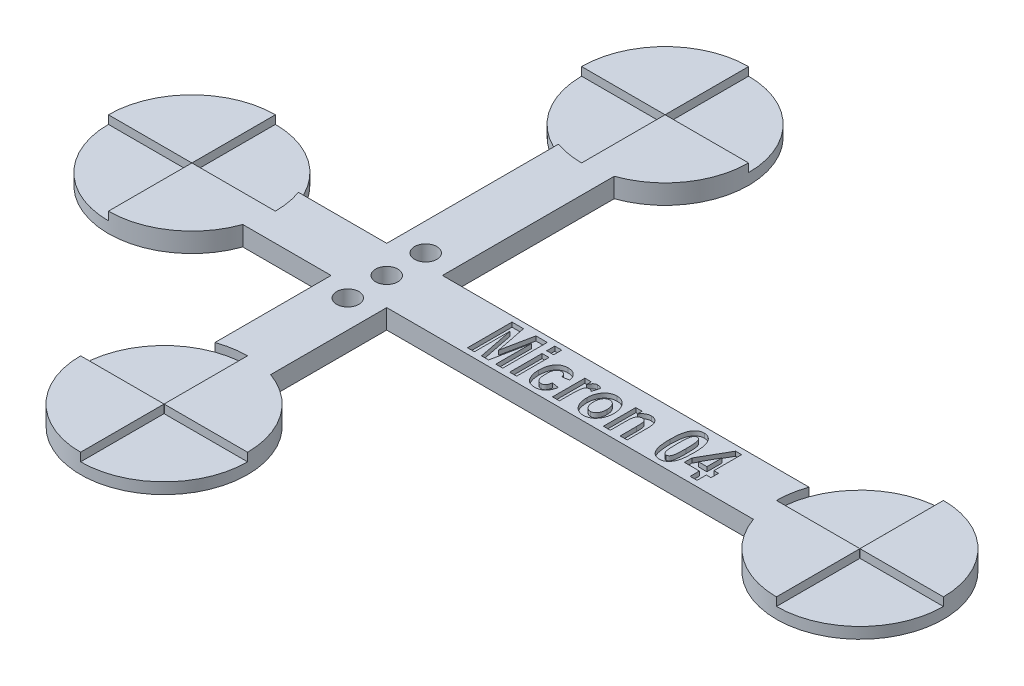
from build123d import *

# Parameters (mm, degrees)
BOSS_EXTRUDE1_DEPTH = 3.5
CUT_EXTRUDE1_DEPTH  = 1.5
SKETCH3_W           = 1.246753247
SKETCH3_H           = 1.454545455
SKETCH3_H_2         = 5.818181818
CUT_EXTRUDE2_DEPTH  = 0.8
SKETCH4_R           = 2
CUT_EXTRUDE3_DEPTH  = 4.5


with BuildPart() as part:
    # Sketch1 → Boss-Extrude1 (new body)
    with BuildSketch(Plane(origin=(0, 0, 0), x_dir=(1, 0, 0), z_dir=(0, 1, 0))):
        with BuildLine():
            Line((30, 35.857864376), (30, 5))
            Line((30, 5), (14.142135624, 5))
            ThreePointArc((14.142135624, 5), (-15, 0), (14.142135624, -5))
            Line((14.142135624, -5), (30, -5))
            Line((30, -5), (30, -25.857864376))
            ThreePointArc((30, -25.857864376), (35, -55), (40, -25.857864376))
            Line((40, -25.857864376), (40, -5))
            Line((40, -5), (105.857864376, -5))
            ThreePointArc((105.857864376, -5), (135, 0), (105.857864376, 5))
            Line((105.857864376, 5), (40, 5))
            Line((40, 5), (40, 35.857864376))
            ThreePointArc((40, 35.857864376), (35, 65), (30, 35.857864376))
        make_face()
    extrude(amount=BOSS_EXTRUDE1_DEPTH)

    # Sketch2 → Cut-Extrude1 (cut)
    with BuildSketch(Plane(origin=(0, 3.5, 0), x_dir=(1, 0, 0), z_dir=(0, 1, 0))):
        with BuildLine():
            Line((-15, 0), (-0.05, 0))
            ThreePointArc((-0.05, 0), (-0.035355339, 0.035355339), (0, 0.05))
            Line((0, 0.05), (0, 15))
            ThreePointArc((0, 15), (10.606601718, 10.606601718), (15, 0))
            Line((15, 0), (0.05, 0))
            ThreePointArc((0.05, 0), (0.035355339, -0.035355339), (0, -0.05))
            Line((0, -0.05), (0, -15))
            ThreePointArc((0, -15), (-10.606601718, -10.606601718), (-15, 0))
        make_face()
        with BuildLine():
            Line((35, 65), (35, 50.05))
            ThreePointArc((35, 50.05), (34.964644661, 50.035355339), (34.95, 50))
            Line((34.95, 50), (20, 50))
            ThreePointArc((20, 50), (24.393398282, 39.393398282), (35, 35))
            Line((35, 35), (35, 49.95))
            ThreePointArc((35, 49.95), (35.035355339, 49.964644661), (35.05, 50))
            Line((35.05, 50), (50, 50))
            ThreePointArc((50, 50), (45.606601718, 60.606601718), (35, 65))
        make_face()
        with BuildLine():
            Line((120, 15), (120, 0.05))
            ThreePointArc((120, 0.05), (120.035355339, 0.035355339), (120.05, 0))
            Line((120.05, 0), (135, 0))
            ThreePointArc((135, 0), (130.606601718, -10.606601718), (120, -15))
            Line((120, -15), (120, -0.05))
            ThreePointArc((120, -0.05), (119.964644661, -0.035355339), (119.95, 0))
            Line((119.95, 0), (105, 0))
            ThreePointArc((105, 0), (109.393398282, 10.606601718), (120, 15))
        make_face()
        with BuildLine():
            Line((20, -40), (34.95, -40))
            ThreePointArc((34.95, -40), (34.964644661, -40.035355339), (35, -40.05))
            Line((35, -40.05), (35, -55))
            ThreePointArc((35, -55), (45.606601718, -50.606601718), (50, -40))
            Line((50, -40), (35.05, -40))
            ThreePointArc((35.05, -40), (35.035355339, -39.964644661), (35, -39.95))
            Line((35, -39.95), (35, -25))
            ThreePointArc((35, -25), (24.393398282, -29.393398282), (20, -40))
        make_face()
    extrude(amount=-CUT_EXTRUDE1_DEPTH, mode=Mode.SUBTRACT)

    # Sketch3 → Cut-Extrude2 (cut)
    with BuildSketch(Plane(origin=(0, 3.5, 0), x_dir=(1, 0, 0), z_dir=(0, 1, 0))):
        Polygon((53.50036076, -4), (53.50036076, 4), (55.563672448, 4), (56.669191928, -1.561688312), (57.795815305, 4), (59.838023097, 4), (59.838023097, -4), (58.59126985, -4), (58.59126985, 2.400974026), (57.290945175, -4), (56.023088032, -4), (54.747114006, 2.400974026), (54.747114006, -4), align=None)
        with Locations((61.708152968, 3.376623377)):
            Rectangle(SKETCH3_W, SKETCH3_H)
        with Locations((61.708152968, -1.090909091)):
            Rectangle(SKETCH3_W, SKETCH3_H_2)
        with BuildLine():
            Line((67.734126993, 0.155844156), (66.487373747, -0.051948052))
            add(Edge.make_bspline(
                [(66.487373747, -0.051948052), (66.475238631, 0.013492139), (66.452160271, 0.137945199), (66.389179941, 0.307989308), (66.312160634, 0.454611766), (66.213055442, 0.573886506), (66.095416345, 0.667213464), (65.958609537, 0.733166985), (65.803936467, 0.772456922), (65.694860886, 0.776912369), (65.638347773, 0.779220779)],
                knots=[0, 0, 0, 0, 0.000199325, 0.000379073, 0.0005418, 0.000693948, 0.000840745, 0.000988855, 0.001146348, 0.001315678, 0.001315678, 0.001315678, 0.001315678], degree=3))
            add(Edge.make_bspline(
                [(65.638347773, 0.779220779), (65.600905429, 0.778062939), (65.527122523, 0.775781331), (65.420010496, 0.755102855), (65.317553938, 0.725549098), (65.222958212, 0.677663569), (65.130758823, 0.622007918), (65.046957124, 0.549315551), (64.968136169, 0.465515202), (64.894709448, 0.369037743), (64.827095322, 0.257785931), (64.770603047, 0.128257783), (64.725083376, -0.018687378), (64.68335517, -0.181979253), (64.653655963, -0.363419746), (64.633180941, -0.562384664), (64.620101663, -0.77850796), (64.618220871, -0.928551854), (64.617243876, -1.006493506)],
                knots=[0, 0, 0, 0, 0.000112201, 0.0002211, 0.00032637, 0.000430923, 0.000538128, 0.000648708, 0.000762403, 0.000882861, 0.001011764, 0.001152033, 0.001305535, 0.001472868, 0.001657284, 0.001856457, 0.002072757, 0.002306574, 0.002306574, 0.002306574, 0.002306574], degree=3))
            add(Edge.make_bspline(
                [(64.617243876, -1.006493506), (64.618261217, -1.092546265), (64.620213954, -1.257720471), (64.632711779, -1.496116795), (64.65538517, -1.714396148), (64.685469478, -1.914085761), (64.725675307, -2.093641007), (64.774055334, -2.254680712), (64.831596703, -2.395907747), (64.899086485, -2.518208897), (64.974173657, -2.623094471), (65.056196277, -2.712538943), (65.142228328, -2.791034021), (65.2374127, -2.851962864), (65.336627186, -2.901864568), (65.442857496, -2.935934853), (65.55464497, -2.95784839), (65.631749283, -2.959966029), (65.670815305, -2.961038961)],
                knots=[0, 0, 0, 0, 0.000258163, 0.000495531, 0.000715862, 0.000916302, 0.00110101, 0.001267389, 0.001420236, 0.001557572, 0.001685521, 0.001806187, 0.001921184, 0.002033748, 0.002144102, 0.002253448, 0.002367432, 0.002484495, 0.002484495, 0.002484495, 0.002484495], degree=3))
            add(Edge.make_bspline(
                [(65.670815305, -2.961038961), (65.72855094, -2.958115137), (65.840148837, -2.952463643), (65.998917272, -2.902884688), (66.141871425, -2.82385793), (66.244914469, -2.730611667), (66.318466989, -2.639969699), (66.370108431, -2.557981246), (66.418545215, -2.464077917), (66.462084604, -2.358060987), (66.501266248, -2.240396767), (66.534349316, -2.110465037), (66.565645908, -1.968673701), (66.582502685, -1.869672225), (66.59126985, -1.818181818)],
                knots=[0, 0, 0, 0, 0.000172842, 0.000334088, 0.000493972, 0.000659525, 0.000747247, 0.000843616, 0.000949622, 0.001063883, 0.001187088, 0.001321358, 0.001465921, 0.001622591, 0.001622591, 0.001622591, 0.001622591], degree=3))
            Line((66.59126985, -1.818181818), (67.838023097, -2.025974026))
            add(Edge.make_bspline(
                [(67.838023097, -2.025974026), (67.821015846, -2.110033143), (67.787894315, -2.273737832), (67.725282574, -2.51019173), (67.648292222, -2.729306841), (67.562922764, -2.933353422), (67.465367894, -3.120817392), (67.35648555, -3.292169834), (67.236010198, -3.447294215), (67.103969601, -3.586117196), (66.960430352, -3.708703947), (66.805564143, -3.814231607), (66.640086257, -3.904896068), (66.462835354, -3.977226655), (66.274845438, -4.034537616), (66.075882267, -4.074640125), (65.865713047, -4.099528833), (65.721752457, -4.102417816), (65.648088032, -4.103896104)],
                knots=[0, 0, 0, 0, 0.000257263, 0.000501018, 0.000733076, 0.000953485, 0.001164055, 0.001366255, 0.001561742, 0.001752349, 0.001940051, 0.002126916, 0.002313611, 0.002505046, 0.002700189, 0.002902356, 0.003113183, 0.003334111, 0.003334111, 0.003334111, 0.003334111], degree=3))
            add(Edge.make_bspline(
                [(65.648088032, -4.103896104), (65.554819841, -4.101887492), (65.37321271, -4.097976423), (65.110471697, -4.053593587), (64.864673186, -3.987367001), (64.639207309, -3.888476021), (64.431834059, -3.764176577), (64.243759839, -3.611361294), (64.073517705, -3.431602628), (63.925921273, -3.224317401), (63.795814013, -2.999463478), (63.681997355, -2.762165056), (63.585965745, -2.513438303), (63.506034653, -2.254410985), (63.446476255, -1.98270864), (63.403410095, -1.700737492), (63.374039392, -1.407542533), (63.371686907, -1.208406699), (63.37049063, -1.107142857)],
                knots=[0, 0, 0, 0, 0.000279523, 0.000544272, 0.000797144, 0.001041429, 0.001280302, 0.001520398, 0.001766145, 0.002020725, 0.002281892, 0.002544739, 0.002809429, 0.003081077, 0.00335717, 0.003643018, 0.003936526, 0.004240206, 0.004240206, 0.004240206, 0.004240206], degree=3))
            add(Edge.make_bspline(
                [(63.37049063, -1.107142857), (63.372239743, -0.987488549), (63.375640625, -0.75483916), (63.405336818, -0.417027711), (63.452726945, -0.100401237), (63.522926455, 0.193547978), (63.609847208, 0.466113039), (63.716501303, 0.716580192), (63.846096582, 0.943069469), (63.991820845, 1.149170928), (64.156114523, 1.330213011), (64.331961705, 1.489088097), (64.520060194, 1.623763244), (64.721234776, 1.733258723), (64.935011157, 1.818073271), (65.160732658, 1.877319248), (65.397782122, 1.916873853), (65.560259998, 1.920318934), (65.643217902, 1.922077922)],
                knots=[0, 0, 0, 0, 0.000358898, 0.000697823, 0.001016501, 0.00131851, 0.001603435, 0.001873935, 0.002133483, 0.002384849, 0.002629678, 0.002865336, 0.003094623, 0.003322001, 0.003550805, 0.003782743, 0.004021075, 0.004269712, 0.004269712, 0.004269712, 0.004269712], degree=3))
            add(Edge.make_bspline(
                [(65.643217902, 1.922077922), (65.71035858, 1.920846466), (65.841687336, 1.918437708), (66.034520622, 1.899106266), (66.217142954, 1.864581364), (66.391368457, 1.819675788), (66.554972261, 1.759740953), (66.709026878, 1.685791916), (66.853826329, 1.599814288), (66.98980103, 1.500415487), (67.115185036, 1.385394066), (67.233134509, 1.256930605), (67.340019014, 1.110862201), (67.439342218, 0.950708523), (67.526615855, 0.773374249), (67.606095879, 0.582082787), (67.676087051, 0.374743093), (67.714406275, 0.230221286), (67.734126993, 0.155844156)],
                knots=[0, 0, 0, 0, 0.000201403, 0.00039395, 0.000580532, 0.000758512, 0.000933129, 0.001102311, 0.00127047, 0.001437685, 0.001606618, 0.001780137, 0.00196001, 0.002148783, 0.002344802, 0.00255222, 0.002769885, 0.003000685, 0.003000685, 0.003000685, 0.003000685], degree=3))
        make_face()
        with BuildLine():
            Line((70.019841279, -4), (68.773088032, -4))
            Line((68.773088032, -4), (68.773088032, 1.818181818))
            Line((68.773088032, 1.818181818), (69.915945175, 1.818181818))
            Line((69.915945175, 1.818181818), (69.915945175, 0.991883117))
            add(Edge.make_bspline(
                [(69.915945175, 0.991883117), (69.940159399, 1.037952881), (69.986797897, 1.126686869), (70.05617644, 1.253336089), (70.123683954, 1.367923953), (70.192594719, 1.467096929), (70.254997633, 1.556811947), (70.319023898, 1.631359029), (70.379881779, 1.694731582), (70.457465413, 1.762170073), (70.560087337, 1.826053482), (70.691232303, 1.882473547), (70.832643067, 1.915363311), (70.929848968, 1.919815142), (70.979256863, 1.922077922)],
                knots=[0, 0, 0, 0, 0.000156131, 0.000300721, 0.000433243, 0.000554812, 0.000662946, 0.000760848, 0.000849244, 0.000926367, 0.001068679, 0.001209792, 0.001353128, 0.001501291, 0.001501291, 0.001501291, 0.001501291], degree=3))
            add(Edge.make_bspline(
                [(70.979256863, 1.922077922), (71.049468143, 1.91886318), (71.189930484, 1.912431875), (71.396264458, 1.852623193), (71.598585759, 1.762131289), (71.72239596, 1.675863479), (71.786075045, 1.631493506)],
                knots=[0, 0, 0, 0, 0.000210176, 0.00042047, 0.000639866, 0.000872208, 0.000872208, 0.000872208, 0.000872208], degree=3))
            Line((71.786075045, 1.631493506), (71.391594526, 0.319805195))
            add(Edge.make_bspline(
                [(71.391594526, 0.319805195), (71.343457298, 0.358255441), (71.252471756, 0.430931343), (71.106176233, 0.509110372), (70.96429064, 0.560954838), (70.869258342, 0.568020125), (70.823412708, 0.571428571)],
                knots=[0, 0, 0, 0, 0.000184416, 0.00034857, 0.000495904, 0.00063323, 0.00063323, 0.00063323, 0.00063323], degree=3))
            add(Edge.make_bspline(
                [(70.823412708, 0.571428571), (70.782505012, 0.569577552), (70.701066257, 0.565892554), (70.584319511, 0.525699903), (70.474380215, 0.46484784), (70.373247856, 0.375884101), (70.28120342, 0.255501948), (70.208770468, 0.094601523), (70.146148418, -0.102439271), (70.107437305, -0.295455124), (70.083085691, -0.477538767), (70.06505598, -0.645297865), (70.050951083, -0.839680763), (70.040281294, -1.060551746), (70.030100881, -1.307830134), (70.023930168, -1.582222395), (70.021131213, -1.883652001), (70.020282911, -2.093614232), (70.019841279, -2.202922078)],
                knots=[0, 0, 0, 0, 0.000122282, 0.000243439, 0.00036627, 0.000497452, 0.000644536, 0.000817347, 0.001023727, 0.001264102, 0.001406673, 0.001574831, 0.001770184, 0.001991255, 0.002238201, 0.002512628, 0.002814594, 0.00314252, 0.00314252, 0.00314252, 0.00314252], degree=3))
            Line((70.019841279, -2.202922078), (70.019841279, -4))
        make_face()
        with BuildLine():
            add(Edge.make_bspline(
                [(71.993867253, -1.00974026), (71.99773938, -0.871492577), (72.005358765, -0.599455473), (72.07087566, -0.202105645), (72.173904845, 0.177168447), (72.298261932, 0.475142281), (72.414852128, 0.700213025), (72.508933594, 0.858166819), (72.610211845, 1.0047968), (72.716400181, 1.140905493), (72.830224235, 1.265802708), (72.948905998, 1.380456268), (73.075551332, 1.483975824), (73.251872281, 1.606243165), (73.48640792, 1.734106031), (73.786697572, 1.843482079), (74.103960535, 1.910979968), (74.321452502, 1.918333961), (74.432178941, 1.922077922)],
                knots=[0, 0, 0, 0, 0.000414499, 0.00081563, 0.001204757, 0.001591247, 0.00178148, 0.00196495, 0.002142367, 0.002315787, 0.002482426, 0.002648908, 0.002810415, 0.002972534, 0.003292157, 0.00360852, 0.00392849, 0.004260331, 0.004260331, 0.004260331, 0.004260331], degree=3))
            add(Edge.make_bspline(
                [(74.432178941, 1.922077922), (74.524844362, 1.919080026), (74.706214487, 1.913212371), (74.970819979, 1.872921067), (75.219608224, 1.802229151), (75.453953528, 1.705294578), (75.670723745, 1.576365199), (75.874437856, 1.423442467), (76.059923504, 1.239208288), (76.228428557, 1.030627633), (76.37997441, 0.803981072), (76.513296238, 0.565748818), (76.625008798, 0.317712454), (76.719657136, 0.061815795), (76.787549524, -0.205805812), (76.840332848, -0.481537671), (76.871889339, -0.767122546), (76.87526987, -0.960420315), (76.876984136, -1.058441558)],
                knots=[0, 0, 0, 0, 0.000277982, 0.000544082, 0.000800519, 0.001052268, 0.001302568, 0.001555169, 0.001814604, 0.002084622, 0.002358372, 0.002631625, 0.002902613, 0.00317376, 0.003448993, 0.003729814, 0.004015574, 0.004309567, 0.004309567, 0.004309567, 0.004309567], degree=3))
            add(Edge.make_bspline(
                [(76.876984136, -1.058441558), (76.876227692, -1.131529258), (76.874729677, -1.276267575), (76.857345801, -1.490737935), (76.832372892, -1.700083082), (76.794451847, -1.904353031), (76.74632035, -2.102762528), (76.686787225, -2.295895078), (76.619804227, -2.484139081), (76.53955722, -2.665021822), (76.453170655, -2.838694854), (76.356567034, -3.000287959), (76.256676902, -3.152976813), (76.14667086, -3.291813358), (76.033747016, -3.423233057), (75.911462009, -3.541439921), (75.783056626, -3.649149424), (75.604551972, -3.775655653), (75.369934842, -3.906802618), (75.071483883, -4.020332864), (74.759616253, -4.091116904), (74.546182896, -4.0996153), (74.438672448, -4.103896104)],
                knots=[0, 0, 0, 0, 0.00021921, 0.00043411, 0.00064513, 0.000851458, 0.001056987, 0.001257262, 0.001457537, 0.001655994, 0.001850563, 0.002039049, 0.002220497, 0.002397475, 0.002570043, 0.002739947, 0.002907061, 0.003072374, 0.003395769, 0.003710226, 0.004027699, 0.00434993, 0.00434993, 0.00434993, 0.00434993], degree=3))
            add(Edge.make_bspline(
                [(74.438672448, -4.103896104), (74.352502729, -4.101341217), (74.183124459, -4.096319241), (73.934716636, -4.058456248), (73.698054839, -3.99479852), (73.472549003, -3.90676201), (73.258016744, -3.793542556), (73.054181778, -3.655526311), (72.864029071, -3.488983811), (72.683779026, -3.302138577), (72.520670531, -3.090331966), (72.380150134, -2.855461331), (72.258457363, -2.600481865), (72.162310721, -2.322961565), (72.085543251, -2.024985427), (72.033233234, -1.70496049), (72.000302919, -1.364326972), (71.996049016, -1.12994916), (71.993867253, -1.00974026)],
                knots=[0, 0, 0, 0, 0.000258443, 0.000508006, 0.000751761, 0.000992327, 0.001232686, 0.001478079, 0.001728994, 0.001989631, 0.002255885, 0.002529003, 0.002809298, 0.003101956, 0.003408675, 0.003731336, 0.004073787, 0.004434356, 0.004434356, 0.004434356, 0.004434356], degree=3))
        make_face()
        with BuildLine():
            add(Edge.make_bspline(
                [(73.2406205, -1.090909091), (73.241193573, -1.161301131), (73.242306492, -1.298003716), (73.261234707, -1.496347271), (73.288602558, -1.681695553), (73.324236438, -1.854514739), (73.376162408, -2.012893615), (73.434745234, -2.159458772), (73.506897923, -2.292206203), (73.589461187, -2.410648066), (73.680939517, -2.51464094), (73.776964817, -2.605361366), (73.875632321, -2.685555047), (73.982414792, -2.746314388), (74.091993225, -2.7960892), (74.205812587, -2.83181335), (74.324708332, -2.854023891), (74.405564639, -2.856089635), (74.446789331, -2.857142857)],
                knots=[0, 0, 0, 0, 0.000211095, 0.000409951, 0.000597062, 0.000773144, 0.000938458, 0.001096426, 0.001246068, 0.00139063, 0.001528684, 0.001660738, 0.001786746, 0.001908974, 0.002028146, 0.002147262, 0.002266036, 0.002389583, 0.002389583, 0.002389583, 0.002389583], degree=3))
            add(Edge.make_bspline(
                [(74.446789331, -2.857142857), (74.486930477, -2.856062286), (74.566168615, -2.853929251), (74.682924616, -2.831796204), (74.794636913, -2.796265769), (74.902095046, -2.746661195), (75.004819397, -2.682536946), (75.103605063, -2.604942025), (75.196824143, -2.512150646), (75.285902055, -2.407554507), (75.367452538, -2.288190002), (75.439332996, -2.15529938), (75.496230932, -2.007207398), (75.548090785, -1.84851973), (75.583928744, -1.674677795), (75.611733592, -1.488309881), (75.627963108, -1.288165559), (75.629460002, -1.150461681), (75.630230889, -1.079545455)],
                knots=[0, 0, 0, 0, 0.000120305, 0.000237481, 0.00035505, 0.000471266, 0.000591549, 0.000717557, 0.000847275, 0.000985501, 0.00112914, 0.00128021, 0.001437568, 0.001604429, 0.001780511, 0.001969228, 0.002169562, 0.00238228, 0.00238228, 0.00238228, 0.00238228], degree=3))
            add(Edge.make_bspline(
                [(75.630230889, -1.079545455), (75.629657673, -1.010234819), (75.628544962, -0.875690947), (75.609642621, -0.680588811), (75.582133444, -0.497953131), (75.546465486, -0.327351399), (75.49521573, -0.170068224), (75.433692654, -0.025632812), (75.362554163, 0.1072581), (75.279265313, 0.225728002), (75.188791642, 0.330494971), (75.093903874, 0.422586459), (74.99490702, 0.50126615), (74.890651683, 0.564846212), (74.782053107, 0.614109415), (74.669460084, 0.65026489), (74.551531628, 0.672061169), (74.471231571, 0.67422738), (74.430555565, 0.675324675)],
                knots=[0, 0, 0, 0, 0.000207849, 0.000403471, 0.000587372, 0.000761868, 0.000925636, 0.001082735, 0.001232376, 0.001376939, 0.001516219, 0.001647099, 0.001773107, 0.001894774, 0.002012466, 0.002130035, 0.002248808, 0.002370734, 0.002370734, 0.002370734, 0.002370734], degree=3))
            add(Edge.make_bspline(
                [(74.430555565, 0.675324675), (74.390416835, 0.674238638), (74.311183466, 0.672094813), (74.194392368, 0.650041164), (74.082343389, 0.614060182), (73.973968514, 0.565297339), (73.870848855, 0.500737434), (73.772125734, 0.422584114), (73.677081903, 0.331022603), (73.588667404, 0.225050714), (73.504100416, 0.107532851), (73.436606876, -0.027537366), (73.372844625, -0.171655992), (73.32568136, -0.331268167), (73.285792867, -0.502358852), (73.261951191, -0.687847561), (73.242143614, -0.884859588), (73.241136929, -1.021045607), (73.2406205, -1.090909091)],
                knots=[0, 0, 0, 0, 0.000120305, 0.000237481, 0.00035505, 0.000472742, 0.000593025, 0.000719033, 0.000849914, 0.000988139, 0.001132702, 0.001283011, 0.00144011, 0.001604937, 0.00178137, 0.001966642, 0.002165497, 0.002374969, 0.002374969, 0.002374969, 0.002374969], degree=3))
        make_face(mode=Mode.SUBTRACT)
        with BuildLine():
            Line((82.175685435, -4), (80.928932188, -4))
            Line((80.928932188, -4), (80.928932188, -1.025974026))
            add(Edge.make_bspline(
                [(80.928932188, -1.025974026), (80.92854282, -0.954543529), (80.927799442, -0.818169062), (80.924356954, -0.622819841), (80.920247564, -0.445806445), (80.911867341, -0.287253276), (80.902241106, -0.147618119), (80.891650159, -0.026736408), (80.87710847, 0.075056785), (80.856368171, 0.184335425), (80.821004006, 0.301543782), (80.764596313, 0.426141455), (80.692774231, 0.534382367), (80.604019629, 0.62160385), (80.506619056, 0.69206755), (80.401915582, 0.743240838), (80.289966246, 0.77397023), (80.213215912, 0.777447079), (80.174062058, 0.779220779)],
                knots=[0, 0, 0, 0, 0.000214292, 0.000409124, 0.000586139, 0.000745437, 0.000885387, 0.001006053, 0.001109364, 0.001193733, 0.001339584, 0.001475415, 0.001602837, 0.00172681, 0.001846644, 0.001962086, 0.002074709, 0.002191998, 0.002191998, 0.002191998, 0.002191998], degree=3))
            add(Edge.make_bspline(
                [(80.174062058, 0.779220779), (80.123447016, 0.776869331), (80.023371597, 0.772220076), (79.878191919, 0.730407315), (79.739286208, 0.667322233), (79.612395844, 0.575023409), (79.495650377, 0.46328544), (79.398737064, 0.328262501), (79.317469986, 0.175298829), (79.268630692, 0.030618942), (79.236032455, -0.101357957), (79.218310317, -0.222713773), (79.199402097, -0.363228665), (79.188161741, -0.524290952), (79.175994029, -0.704955422), (79.168471275, -0.905793407), (79.163505023, -1.126597226), (79.162974738, -1.280299629), (79.162698422, -1.36038961)],
                knots=[0, 0, 0, 0, 0.000151532, 0.000299606, 0.000449951, 0.00060715, 0.000767873, 0.000932819, 0.001103467, 0.001285727, 0.00138928, 0.001510979, 0.001653337, 0.001814575, 0.001995128, 0.00219659, 0.002417423, 0.002657688, 0.002657688, 0.002657688, 0.002657688], degree=3))
            Line((79.162698422, -1.36038961), (79.162698422, -4))
            Line((79.162698422, -4), (77.915945175, -4))
            Line((77.915945175, -4), (77.915945175, 1.818181818))
            Line((77.915945175, 1.818181818), (79.058802318, 1.818181818))
            Line((79.058802318, 1.818181818), (79.058802318, 0.965909091))
            add(Edge.make_bspline(
                [(79.058802318, 0.965909091), (79.109710936, 1.041759386), (79.208544913, 1.189015129), (79.378208436, 1.383777654), (79.556148861, 1.549983921), (79.743871586, 1.687067674), (79.943914365, 1.791672469), (80.153616398, 1.866743358), (80.373756253, 1.914536504), (80.524465529, 1.919537791), (80.60101011, 1.922077922)],
                knots=[0, 0, 0, 0, 0.000273831, 0.000531616, 0.00077285, 0.001003084, 0.001226733, 0.001447536, 0.001669767, 0.001899129, 0.001899129, 0.001899129, 0.001899129], degree=3))
            add(Edge.make_bspline(
                [(80.60101011, 1.922077922), (80.688429859, 1.918919658), (80.857463892, 1.912812868), (81.100755155, 1.857826735), (81.32221213, 1.766788484), (81.519497148, 1.639484009), (81.693501252, 1.488180451), (81.837925118, 1.311212589), (81.955005756, 1.115344188), (82.024073318, 0.933951844), (82.069245622, 0.777526046), (82.097815568, 0.646198938), (82.122467785, 0.502145243), (82.140849457, 0.345447453), (82.157608055, 0.176651439), (82.168642166, -0.004744055), (82.17517168, -0.198542646), (82.175511007, -0.332245522), (82.175685435, -0.400974026)],
                knots=[0, 0, 0, 0, 0.000261973, 0.000506549, 0.000743812, 0.00097664, 0.00120785, 0.001432751, 0.0016591, 0.001889414, 0.002012726, 0.002147427, 0.002292345, 0.002451013, 0.002620623, 0.002801175, 0.002996089, 0.003202264, 0.003202264, 0.003202264, 0.003202264], degree=3))
            Line((82.175685435, -0.400974026), (82.175685435, -4))
        make_face()
        with BuildLine():
            add(Edge.make_bspline(
                [(88.042568552, 4), (88.120143484, 3.997148674), (88.273215628, 3.991522391), (88.496552113, 3.948267667), (88.709167709, 3.877994443), (88.909593475, 3.778303449), (89.097951861, 3.649902676), (89.274716094, 3.493575316), (89.44002471, 3.309388361), (89.594940829, 3.095688722), (89.734153575, 2.845756266), (89.853050654, 2.555093261), (89.952904602, 2.222696136), (90.034271056, 1.848605187), (90.098816614, 1.432288922), (90.142527697, 0.973709188), (90.170357365, 0.473287901), (90.173862882, 0.125581293), (90.175685435, -0.055194805)],
                knots=[0, 0, 0, 0, 0.000232602, 0.000458974, 0.000679718, 0.0009026, 0.001128179, 0.00136168, 0.001608802, 0.001869231, 0.002151946, 0.002464883, 0.002809456, 0.003191901, 0.003612528, 0.004072572, 0.004573333, 0.005115628, 0.005115628, 0.005115628, 0.005115628], degree=3))
            add(Edge.make_bspline(
                [(90.175685435, -0.055194805), (90.173858892, -0.235429027), (90.170346113, -0.582052681), (90.14257855, -1.080864069), (90.098621978, -1.538317484), (90.034600767, -1.953666632), (89.952257764, -2.327486698), (89.853811541, -2.659813141), (89.733670888, -2.949980575), (89.595090938, -3.199694145), (89.439887399, -3.412685451), (89.276378827, -3.597979093), (89.099525864, -3.753792128), (88.911527253, -3.881710441), (88.71208139, -3.98233668), (88.500748445, -4.05159659), (88.278700656, -4.095734493), (88.126655602, -4.101138343), (88.049062058, -4.103896104)],
                knots=[0, 0, 0, 0, 0.000540672, 0.001039812, 0.00149824, 0.001918867, 0.002299728, 0.002645854, 0.002957293, 0.003240007, 0.003500437, 0.003746473, 0.003979974, 0.004205554, 0.004426982, 0.004647726, 0.004870909, 0.005103511, 0.005103511, 0.005103511, 0.005103511], degree=3))
            add(Edge.make_bspline(
                [(88.049062058, -4.103896104), (87.971520172, -4.100862637), (87.818612265, -4.094880825), (87.59489671, -4.054282938), (87.382435066, -3.983452229), (87.182511086, -3.883672907), (86.993665393, -3.757214281), (86.816991446, -3.602360262), (86.651459776, -3.419950023), (86.525616278, -3.246353686), (86.430990718, -3.092878847), (86.364980322, -2.964508803), (86.303455869, -2.825479381), (86.244235797, -2.676576112), (86.19349064, -2.514885831), (86.144536647, -2.343474895), (86.100591604, -2.160968409), (86.062673394, -1.967931987), (86.02559404, -1.76477297), (85.998032431, -1.550003327), (85.97076078, -1.325090023), (85.952664467, -1.088321983), (85.93572137, -0.841612758), (85.925283351, -0.583390093), (85.915909942, -0.315001944), (85.915933294, -0.132043959), (85.915945175, -0.038961039)],
                knots=[0, 0, 0, 0, 0.000232602, 0.000458677, 0.000679421, 0.000902303, 0.001126975, 0.001359407, 0.001605326, 0.001864441, 0.002001422, 0.002145912, 0.00229706, 0.002457438, 0.002626339, 0.002805176, 0.002992203, 0.003189274, 0.003395315, 0.003611584, 0.003838724, 0.004074918, 0.004323825, 0.00458057, 0.004850172, 0.005129398, 0.005129398, 0.005129398, 0.005129398], degree=3))
            add(Edge.make_bspline(
                [(85.915945175, -0.038961039), (85.917766425, 0.140733062), (85.92126861, 0.486277146), (85.949096706, 0.983455445), (85.992786068, 1.438795514), (86.057455354, 1.852398974), (86.139031184, 2.224773358), (86.238156972, 2.556355193), (86.357927524, 2.84609395), (86.496547236, 3.095795814), (86.651741372, 3.308789888), (86.815252237, 3.494082856), (86.992104631, 3.649896058), (87.180103387, 3.777814329), (87.379549212, 3.878440579), (87.590882167, 3.947700486), (87.812929954, 3.99183839), (87.964975007, 3.997242239), (88.042568552, 4)],
                knots=[0, 0, 0, 0, 0.000539049, 0.001036568, 0.001493381, 0.0019108, 0.002291661, 0.002636234, 0.002947673, 0.003230387, 0.003490817, 0.003736853, 0.003970355, 0.004195934, 0.004417363, 0.004638106, 0.004861289, 0.005093891, 0.005093891, 0.005093891, 0.005093891], degree=3))
        make_face()
        with BuildLine():
            add(Edge.make_bspline(
                [(88.045815305, 2.753246753), (88.016983802, 2.751588419), (87.959509622, 2.748282613), (87.875927262, 2.724571332), (87.79639698, 2.686845816), (87.722427151, 2.631936572), (87.654531179, 2.560572149), (87.589331771, 2.475933398), (87.529382821, 2.37557449), (87.471821912, 2.257031527), (87.422907436, 2.108173752), (87.379831447, 1.922528032), (87.345944957, 1.69496366), (87.317590249, 1.425720345), (87.292957589, 1.115056325), (87.278036586, 0.762026881), (87.268158161, 0.367481909), (87.267133043, 0.090375275), (87.266594526, -0.055194805)],
                knots=[0, 0, 0, 0, 8.6421e-05, 0.000172276, 0.000258682, 0.000349271, 0.00044685, 0.000553351, 0.00066917, 0.000796964, 0.000947894, 0.001138079, 0.00136814, 0.001637587, 0.001950225, 0.002302871, 0.002697472, 0.003134172, 0.003134172, 0.003134172, 0.003134172], degree=3))
            add(Edge.make_bspline(
                [(87.266594526, -0.055194805), (87.267123328, -0.200765322), (87.268127989, -0.477331814), (87.278100069, -0.871330634), (87.29283468, -1.223292397), (87.317841907, -1.533920343), (87.34564763, -1.80268425), (87.37998794, -2.030198873), (87.42300039, -2.215269381), (87.471382223, -2.36384325), (87.52979398, -2.481451586), (87.589390764, -2.581371854), (87.653964499, -2.666118067), (87.722995564, -2.735808707), (87.79633331, -2.790804977), (87.875943778, -2.828451078), (87.959505472, -2.852182826), (88.016982415, -2.855485896), (88.045815305, -2.857142857)],
                knots=[0, 0, 0, 0, 0.0004367, 0.000829678, 0.001182325, 0.001493344, 0.001764405, 0.001992863, 0.002183047, 0.002333978, 0.002460309, 0.002576128, 0.002682629, 0.002779053, 0.002869643, 0.002956049, 0.003041904, 0.003128325, 0.003128325, 0.003128325, 0.003128325], degree=3))
            add(Edge.make_bspline(
                [(88.045815305, -2.857142857), (88.075188368, -2.85552029), (88.133206372, -2.852315378), (88.21738504, -2.828542533), (88.297029049, -2.790253808), (88.372435814, -2.736496976), (88.439646108, -2.664443264), (88.506337432, -2.581825172), (88.563423586, -2.480471516), (88.621525538, -2.362653873), (88.670754282, -2.213878514), (88.710709098, -2.027621166), (88.748134759, -1.800724279), (88.775757394, -1.53179805), (88.798173843, -1.221589379), (88.813727392, -0.869719468), (88.823431124, -0.476245826), (88.824483267, -0.20022291), (88.825036084, -0.055194805)],
                knots=[0, 0, 0, 0, 8.8037e-05, 0.000173892, 0.000260298, 0.000352202, 0.00044978, 0.000554999, 0.000669985, 0.000797778, 0.000948709, 0.001138526, 0.001368845, 0.001638291, 0.001949188, 0.002301835, 0.002694813, 0.00312989, 0.00312989, 0.00312989, 0.00312989], degree=3))
            add(Edge.make_bspline(
                [(88.825036084, -0.055194805), (88.824478904, 0.090374192), (88.823418258, 0.367478764), (88.813778191, 0.762037569), (88.798092676, 1.114981824), (88.775844364, 1.425743409), (88.748129467, 1.695205512), (88.710705916, 1.922098251), (88.670766677, 2.108368799), (88.621491087, 2.257107732), (88.563526869, 2.37503186), (88.505793041, 2.476420917), (88.440190416, 2.560429298), (88.372374904, 2.632553578), (88.297043894, 2.68636923), (88.217381216, 2.724643459), (88.133207354, 2.748420037), (88.075188698, 2.751624443), (88.045815305, 2.753246753)],
                knots=[0, 0, 0, 0, 0.0004367, 0.000831301, 0.001183948, 0.001496464, 0.00176591, 0.001996229, 0.002186046, 0.002336977, 0.00246477, 0.002579756, 0.002686257, 0.002783835, 0.002875739, 0.002962145, 0.003048, 0.003136037, 0.003136037, 0.003136037, 0.003136037], degree=3))
        make_face(mode=Mode.SUBTRACT)
        Polygon((93.50036076, -4), (93.50036076, -2.337662338), (90.799062058, -2.337662338), (90.799062058, -0.991883117), (93.662698422, 4), (94.747114006, 4), (94.747114006, -0.987012987), (95.578282837, -0.987012987), (95.578282837, -2.337662338), (94.747114006, -2.337662338), (94.747114006, -4), align=None)
        Polygon((93.50036076, -0.987012987), (93.50036076, 1.699675325), (91.98575037, -0.987012987), align=None, mode=Mode.SUBTRACT)
    extrude(amount=-CUT_EXTRUDE2_DEPTH, mode=Mode.SUBTRACT)

    # Sketch4 → Cut-Extrude3 (cut, through all)
    with BuildSketch(Plane(origin=(0, 3.5, 0), x_dir=(1, 0, 0), z_dir=(0, 1, 0))):
        with Locations((35, 0)):
            Circle(SKETCH4_R)
        with Locations((35, 7)):
            Circle(SKETCH4_R)
        with Locations((35, -7)):
            Circle(SKETCH4_R)
    extrude(amount=-CUT_EXTRUDE3_DEPTH, mode=Mode.SUBTRACT)


solid = part.part
